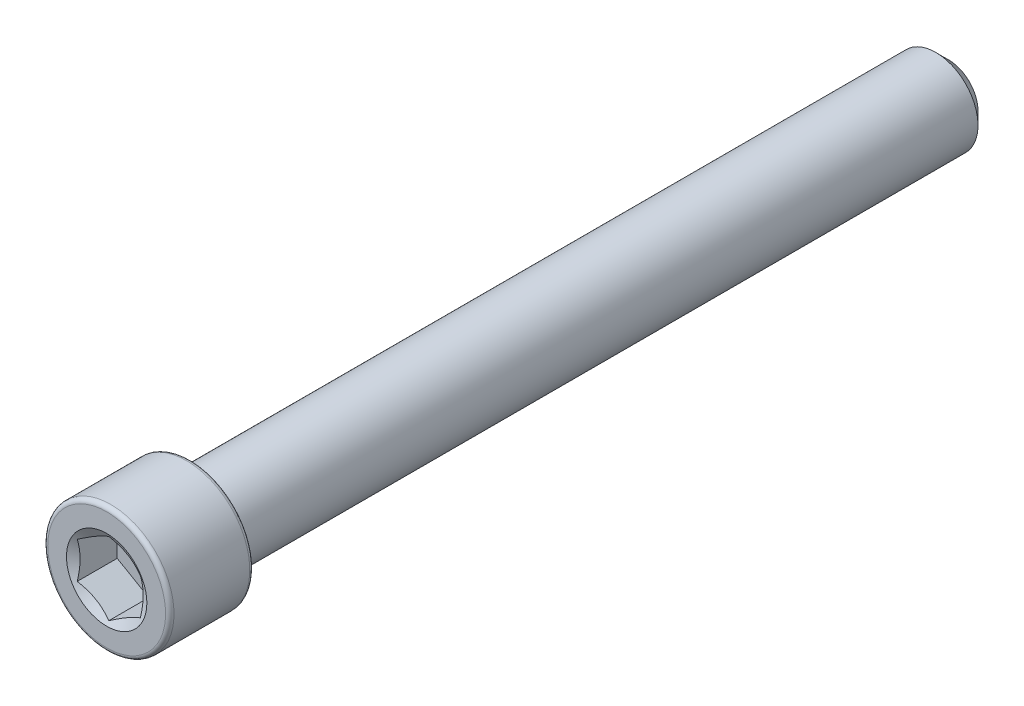
from build123d import *

# Parameters (mm, degrees)
CUT_EXTRUDE1_START = 31.75
CUT_EXTRUDE1_DEPTH = 3.175


with BuildPart() as part:
    # Sketch2 → Revolve1 (revolve)
    with BuildSketch(Plane(origin=(0, 0, 0), x_dir=(0, 0, -1), z_dir=(1, 0, 0)), mode=Mode.PRIVATE) as revolve1_sk:
        with BuildLine():
            Line((31.75, 0), (31.75, 2.2225))
            Line((31.75, 2.2225), (30.7975, 3.175))
            Line((30.7975, 3.175), (-25.4, 3.175))
            Line((-25.4, 3.175), (-25.4, 4.445))
            ThreePointArc((-25.4, 4.445), (-25.492993597, 4.669506403), (-25.7175, 4.7625))
            Line((-25.7175, 4.7625), (-31.4325, 4.7625))
            ThreePointArc((-31.4325, 4.7625), (-31.657006403, 4.669506403), (-31.75, 4.445))
            Line((-31.75, 4.445), (-31.75, 0))
            Line((-31.75, 0), (31.75, 0))
        make_face()
    revolve(revolve1_sk.sketch.rotate(Axis((0, 0, -31.75), (0, 0, 1)), 90), axis=Axis((0, 0, -31.75), (0, 0, 1)))

    # Sketch3 → Cut-Extrude1 (cut)
    with BuildSketch(Plane.XY.offset(CUT_EXTRUDE1_START)):
        Polygon((-2.38125, 1.374815329), (-2.38125, -1.374815329), (0, -2.749630657), (2.38125, -1.374815329), (2.38125, 1.374815329), (0, 2.749630657), align=None)
    extrude(amount=-CUT_EXTRUDE1_DEPTH, mode=Mode.SUBTRACT)

    # Cut-Extrude2 cone 1 section (through the dimple's axis) → Cut-Extrude2 (revolve, cut)
    with BuildSketch(Plane(origin=(0, 0, 31.75), x_dir=(0, -1, 0), z_dir=(1, 0, 0))):
        Polygon((0, 0), (3.032192214, 0), (0, 1.750636991), align=None)
    revolve(axis=Axis((0, 0, 31.75), (0, 0, -1)), mode=Mode.SUBTRACT)


solid = part.part
